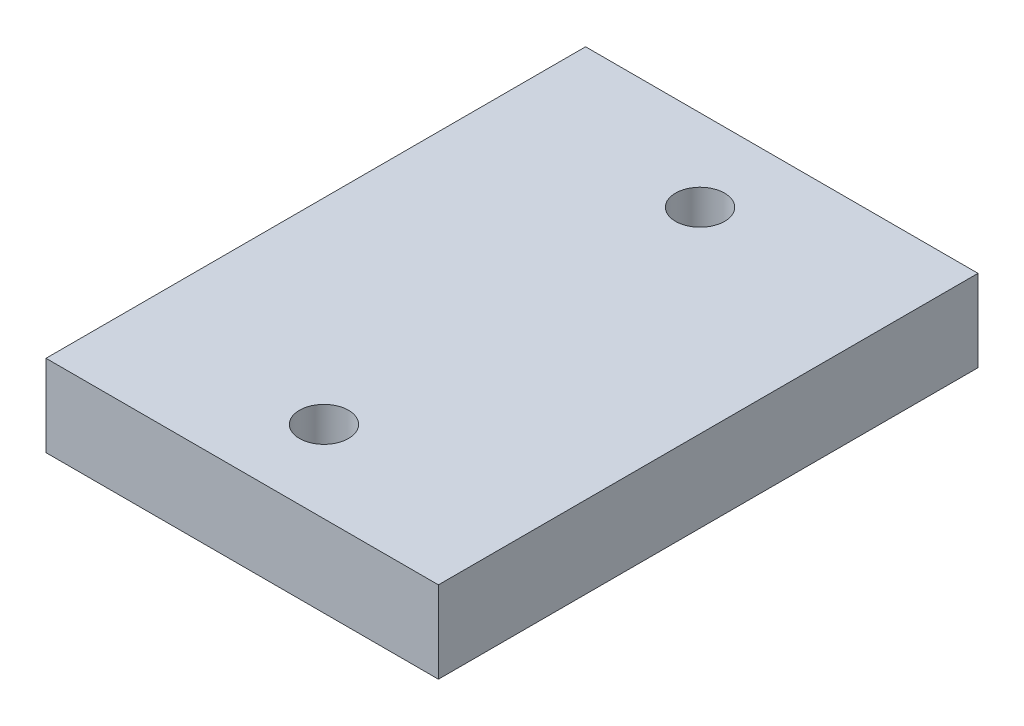
from build123d import *

# Parameters (mm, degrees)
SKETCH1_W           = 24
SKETCH1_H           = 33
SKETCH1_R           = 1.5
BOSS_EXTRUDE1_DEPTH = 5


with BuildPart() as part:
    # Sketch1 → Boss-Extrude1 (new body)
    with BuildSketch(Plane(origin=(0, 0, 0), x_dir=(1, 0, 0), z_dir=(0, 1, 0))):
        Rectangle(SKETCH1_W, SKETCH1_H)
        with Locations((0, 11.5)):
            Circle(SKETCH1_R, mode=Mode.SUBTRACT)
        with Locations((0, -11.5)):
            Circle(SKETCH1_R, mode=Mode.SUBTRACT)
    extrude(amount=BOSS_EXTRUDE1_DEPTH)


solid = part.part
